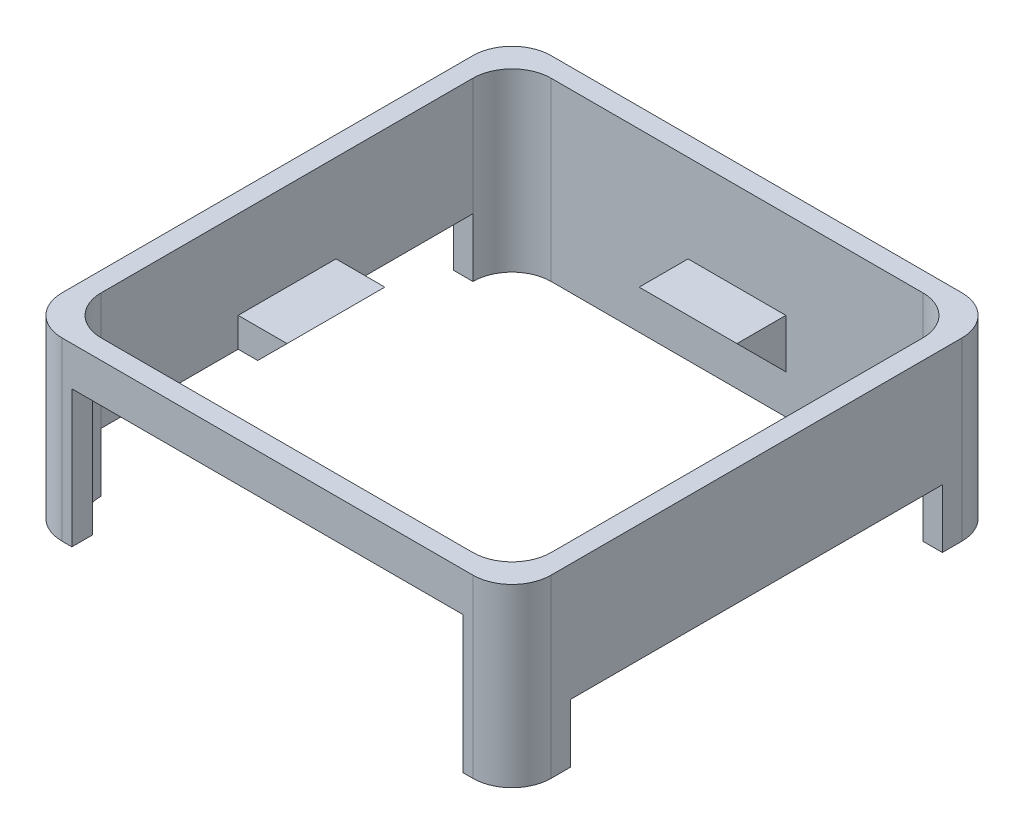
from build123d import *

# Parameters (mm, degrees)
SKETCH1_W           = 250
SKETCH1_H           = 250
SKETCH1_W_2         = 230
SKETCH1_H_2         = 230
BOSS_EXTRUDE1_DEPTH = 90
SKETCH2_W           = 200
SKETCH2_H           = 70
CUT_EXTRUDE1_DEPTH  = 50
FILLET1_R           = 20
BOSS_EXTRUDE2_DEPTH = 25
BOSS_EXTRUDE3_DEPTH = 25
SKETCH6_W           = 190
SKETCH6_H           = 30
CUT_EXTRUDE2_DEPTH  = 251


with BuildPart() as part:
    # Sketch1 → Boss-Extrude1 (new body)
    with BuildSketch(Plane(origin=(0, 0, 0), x_dir=(1, 0, 0), z_dir=(0, 1, 0))):
        Rectangle(SKETCH1_W, SKETCH1_H)
        Rectangle(SKETCH1_W_2, SKETCH1_H_2, mode=Mode.SUBTRACT)
    extrude(amount=BOSS_EXTRUDE1_DEPTH)

    # Sketch2 → Cut-Extrude1 (cut)
    with BuildSketch(Plane.XY.offset(125)):
        with Locations((0, 35)):
            Rectangle(SKETCH2_W, SKETCH2_H)
    extrude(amount=-CUT_EXTRUDE1_DEPTH, mode=Mode.SUBTRACT)

    # Fillet1
    fillet1_edges = [part.edges().sort_by_distance(p)[0] for p in [
        (-115, 45, 115),
        (115, 45, 115),
        (115, 45, -115),
        (-115, 45, -115),
        (-125, 45, 125),
        (125, 45, 125),
        (125, 45, -125),
        (-125, 45, -125),
    ]]
    fillet(fillet1_edges, radius=FILLET1_R)

    # Sketch4 → Boss-Extrude2 (add, symmetric)
    with BuildSketch(Plane.XY):
        Polygon((-115, 45), (-90, 45), (-115, 20), align=None)
        Polygon((115, 45), (90, 45), (115, 20), align=None)
    extrude(amount=BOSS_EXTRUDE2_DEPTH, both=True)

    # Sketch5 → Boss-Extrude3 (add, symmetric)
    with BuildSketch(Plane(origin=(0, 0, 0), x_dir=(0, 0, -1), z_dir=(1, 0, 0))):
        Polygon((115, 45), (115, 20), (90, 45), align=None)
    extrude(amount=BOSS_EXTRUDE3_DEPTH, both=True)

    # Sketch6 → Cut-Extrude2 (cut, through all)
    with BuildSketch(Plane(origin=(125, 0, 0), x_dir=(0, 0, -1), z_dir=(1, 0, 0))):
        with Locations((0, 15)):
            Rectangle(SKETCH6_W, SKETCH6_H)
    extrude(amount=-CUT_EXTRUDE2_DEPTH, mode=Mode.SUBTRACT)


solid = part.part
